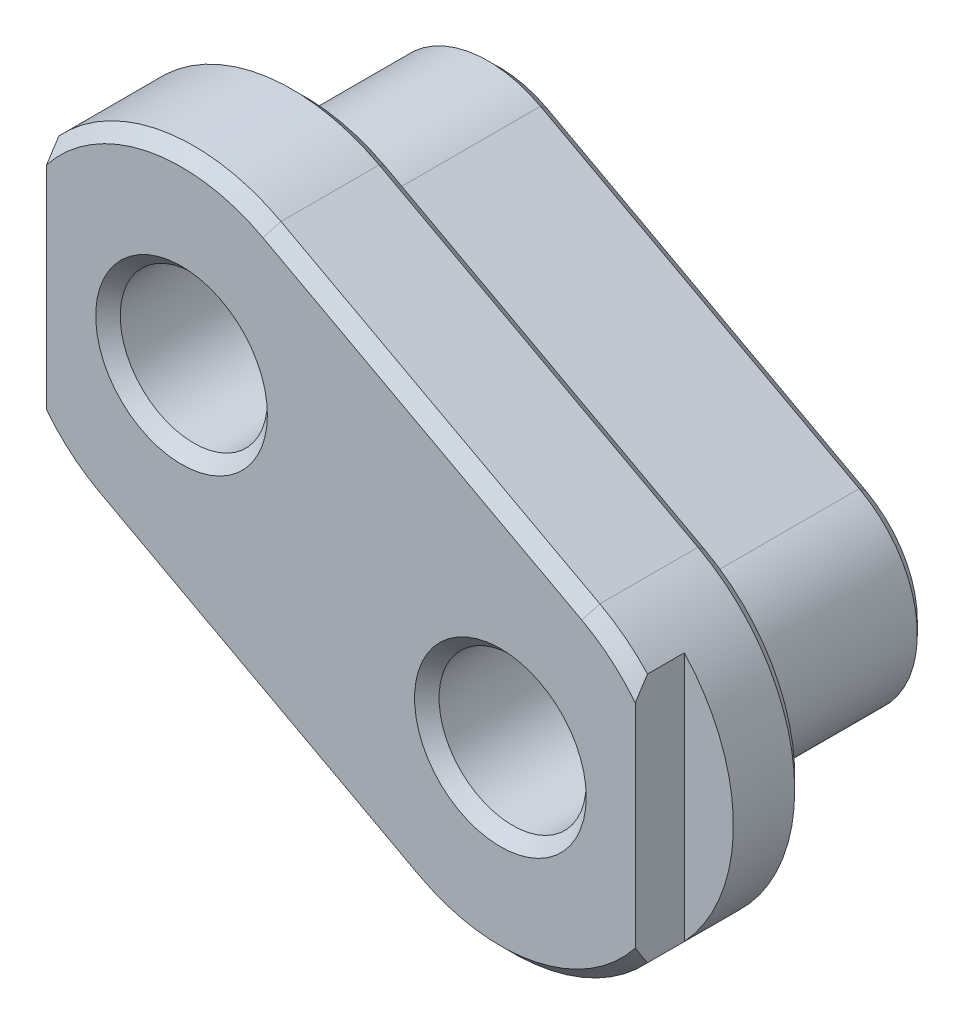
from build123d import *

# Parameters (mm, degrees)
EXTRUDE_1_DEPTH     = 16
EXTRUDE_2_DEPTH     = 10
CUT_EXTRUDE_1_DEPTH = 4
SKETCH_4_R          = 6
CUT_EXTRUDE_2_DEPTH = 27
CHAMFER_1_SIZE      = 1


with BuildPart() as part:
    # 草图1 → 凸台-拉伸1 (new body)
    with BuildSketch(Plane.XY):
        with BuildLine():
            Line((-30.266898407, 6.075760101), (-4.266898407, -7.924239899))
            ThreePointArc((-4.266898407, -7.924239899), (7.924239899, -4.266898407), (4.266898407, 7.924239899))
            Line((4.266898407, 7.924239899), (-21.733101593, 21.924239899))
            ThreePointArc((-21.733101593, 21.924239899), (-33.924239899, 18.266898407), (-30.266898407, 6.075760101))
        make_face()
    extrude(amount=EXTRUDE_1_DEPTH)

    # 草图2 → 凸台-拉伸2 (add)
    with BuildSketch(Plane.XY.offset(16)):
        with BuildLine():
            Line((7.111497346, 13.207066499), (-18.888502654, 27.207066499))
            ThreePointArc((-18.888502654, 27.207066499), (-39.207066499, 21.111497346), (-33.111497346, 0.792933501))
            Line((-33.111497346, 0.792933501), (-7.111497346, -13.207066499))
            ThreePointArc((-7.111497346, -13.207066499), (13.207066499, -7.111497346), (7.111497346, 13.207066499))
        make_face()
    extrude(amount=EXTRUDE_2_DEPTH)

    # 草图3 → 切除-拉伸1 (cut)
    with BuildSketch(Plane.XY.offset(26)):
        with BuildLine():
            Line((-37, 24.198039027), (-37, 3.801960973))
            ThreePointArc((-37, 3.801960973), (-41, 14), (-37, 24.198039027))
        make_face()
        with BuildLine():
            Line((11, 10.198039027), (11, -10.198039027))
            ThreePointArc((11, -10.198039027), (15, 0), (11, 10.198039027))
        make_face()
    extrude(amount=-CUT_EXTRUDE_1_DEPTH, mode=Mode.SUBTRACT)

    # 草图4 → 切除-拉伸2 (cut, through all)
    with BuildSketch(Plane(origin=(0, 0, 0), x_dir=(-1, 0, 0), z_dir=(0, 0, -1))):
        Circle(SKETCH_4_R)
        with Locations((26, 14)):
            Circle(SKETCH_4_R)
    extrude(amount=-CUT_EXTRUDE_2_DEPTH, mode=Mode.SUBTRACT)

    # 倒角1
    chamfer_1_edges = [part.edges().sort_by_distance(p)[0] for p in [
        (13.207066499, -7.111497346, 16),
        (-5.888502654, 20.207066499, 16),
        (-39.207066499, 21.111497346, 16),
        (-20.111497346, -6.207066499, 16),
        (2.45838866, -14.797172878, 26),
        (-5.888502654, 20.207066499, 26),
        (-28.45838866, 28.797172878, 26),
        (-20.111497346, -6.207066499, 26),
        (9.179877211, 11.862961451, 26),
        (-35.179877211, 2.137038549, 26),
        (-17.266898407, -0.924239899, 0),
        (6, 0, 26),
        (6, 0, 0),
        (-20, 14, 26),
        (-20, 14, 0),
        (-33.924239899, 18.266898407, 0),
        (-8.733101593, 14.924239899, 0),
        (7.924239899, -4.266898407, 0),
    ]]
    chamfer(chamfer_1_edges, length=CHAMFER_1_SIZE)


solid = part.part
